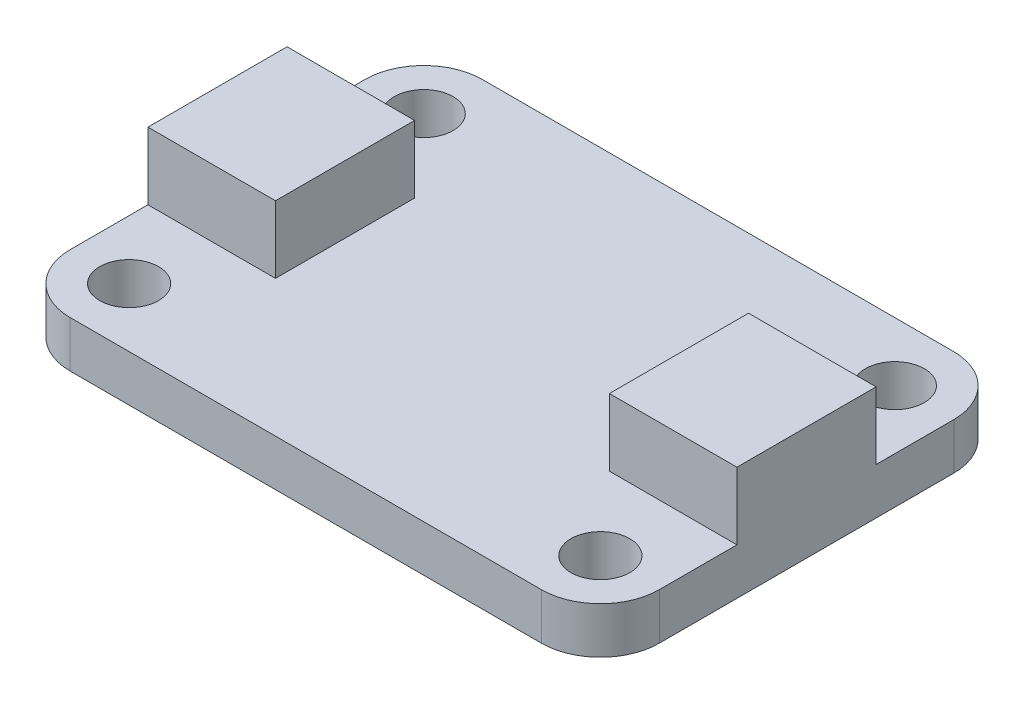
from build123d import *

# Parameters (mm, degrees)
SKETCH1_W           = 25.4
SKETCH1_H           = 17.78
BOSS_EXTRUDE1_DEPTH = 2
SKETCH2_R           = 1.27
CUT_EXTRUDE1_DEPTH  = 3
SKETCH3_W           = 5.5
SKETCH3_H           = 6
BOSS_EXTRUDE2_DEPTH = 2.9
FILLET1_R           = 2.54


with BuildPart() as part:
    # Sketch1 → Boss-Extrude1 (new body)
    with BuildSketch(Plane(origin=(0, 0, 0), x_dir=(1, 0, 0), z_dir=(0, 1, 0))):
        with Locations((12.7, 8.89)):
            Rectangle(SKETCH1_W, SKETCH1_H)
    extrude(amount=BOSS_EXTRUDE1_DEPTH)

    # Sketch2 → Cut-Extrude1 (cut, through all)
    with BuildSketch(Plane(origin=(0, 2, 0), x_dir=(1, 0, 0), z_dir=(0, 1, 0))):
        with Locations((2.54, 15.24)):
            Circle(SKETCH2_R)
        with Locations((22.86, 15.24)):
            Circle(SKETCH2_R)
        with Locations((22.86, 2.54)):
            Circle(SKETCH2_R)
        with Locations((2.54, 2.54)):
            Circle(SKETCH2_R)
    extrude(amount=-CUT_EXTRUDE1_DEPTH, mode=Mode.SUBTRACT)

    # Sketch3 → Boss-Extrude2 (add)
    with BuildSketch(Plane(origin=(0, 2, 0), x_dir=(1, 0, 0), z_dir=(0, 1, 0))):
        with Locations((22.65, 8.89)):
            Rectangle(SKETCH3_W, SKETCH3_H)
        with Locations((2.75, 8.89)):
            Rectangle(SKETCH3_W, SKETCH3_H)
    extrude(amount=BOSS_EXTRUDE2_DEPTH)

    # Fillet1
    fillet1_edges = [part.edges().sort_by_distance(p)[0] for p in [
        (0, 1, -17.78),
        (25.4, 1, -17.78),
        (25.4, 1, 0),
        (0, 1, 0),
    ]]
    fillet(fillet1_edges, radius=FILLET1_R)


solid = part.part
